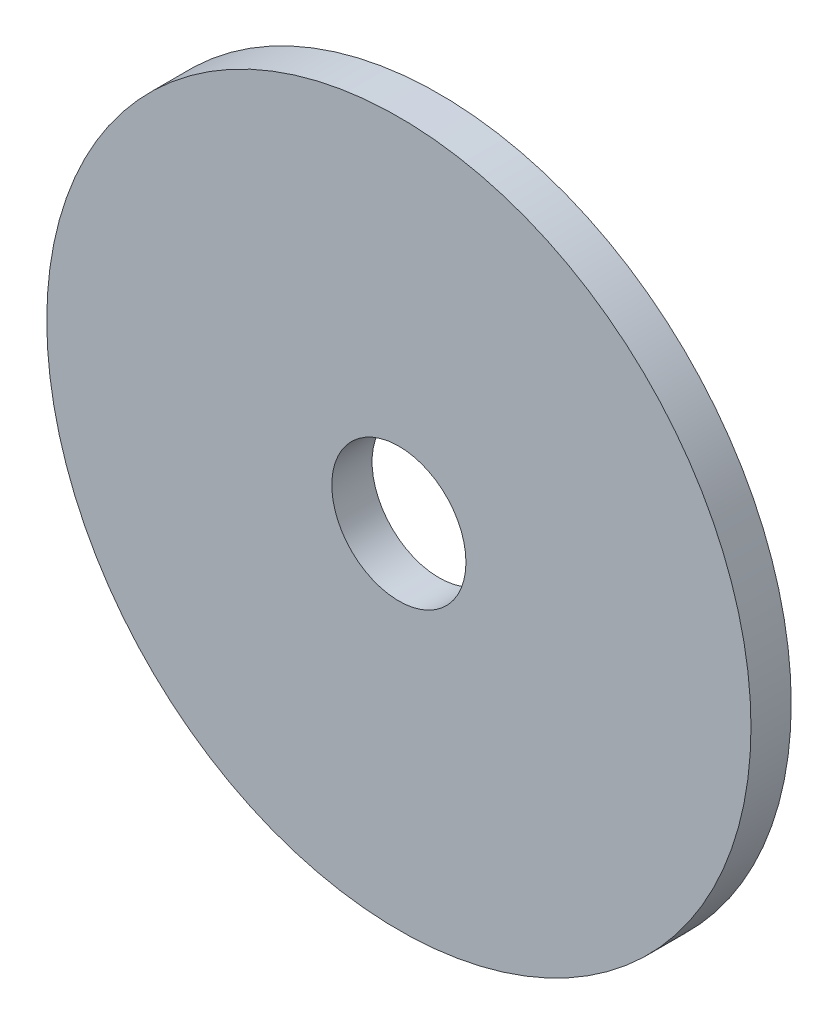
from build123d import *

# Parameters (mm, degrees)
ESQUISSE1_R        = 52.5
ESQUISSE1_R_2      = 10
BOSS_EXTRU_1_DEPTH = 6


with BuildPart() as part:
    # Esquisse1 → Boss.-Extru.1 (new body)
    with BuildSketch(Plane.XY):
        Circle(ESQUISSE1_R)
        Circle(ESQUISSE1_R_2, mode=Mode.SUBTRACT)
    extrude(amount=BOSS_EXTRU_1_DEPTH)


solid = part.part
